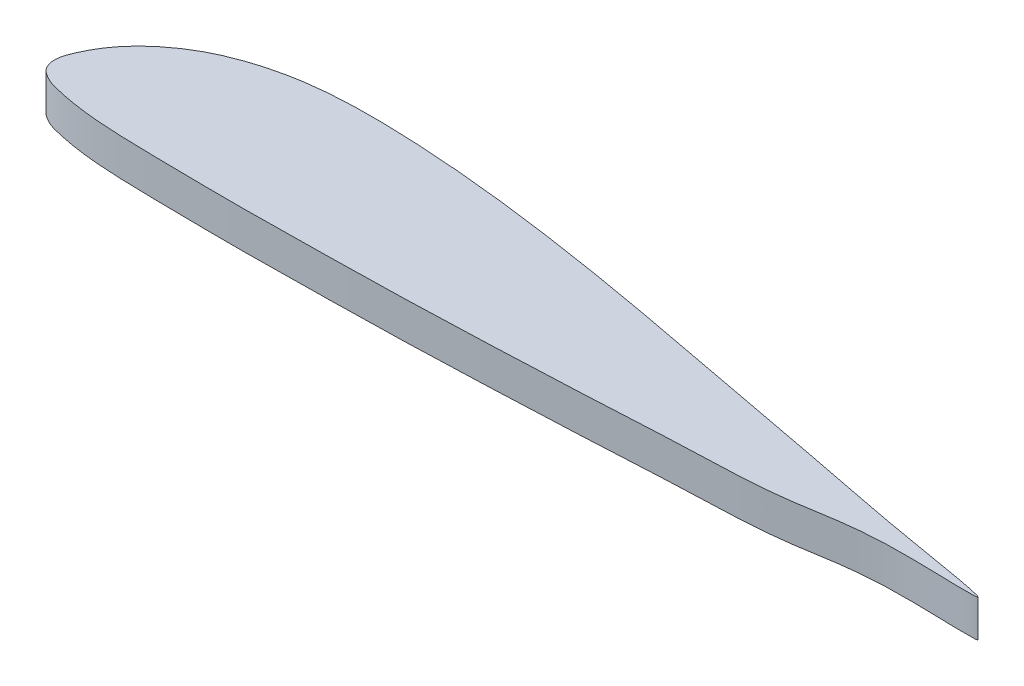
from build123d import *

# Parameters (mm, degrees)
BOSS_EXTRUDE2_DEPTH = 4


with BuildPart() as part:
    # Sketch2 → Boss-Extrude2 (new body)
    with BuildSketch(Plane(origin=(0, 0, 0), x_dir=(1, 0, 0), z_dir=(0, 1, 0))):
        with BuildLine():
            add(Edge.make_bspline(
                [(100, 0), (100.062832481, 0.251035491), (88.423782974, 2.077171545), (80.42251087, 3.753346357), (69.886173545, 5.709443028), (60.038664734, 7.607750011), (50.016738031, 9.448794891), (40.032646993, 10.974024804), (31.681442376, 11.857617234), (25.003732925, 12.218802233), (19.991287342, 12.255901671), (14.932026744, 11.831525262), (10.552698907, 10.717194811), (7.226014658, 9.264268293), (4.894142811, 7.740900366), (3.227317175, 6.302068696), (1.907577305, 4.784574924), (1.090513349, 3.517602977), (0.31110434, 1.94974357), (-0.274693213, 0.387957211), (0.322414802, -0.985991259), (1.128085986, -1.553275899), (1.960743073, -1.980402203), (3.325075799, -2.314398918), (4.988474859, -2.651519441), (7.325893482, -2.960829773), (10.662702275, -3.183298157), (14.99974317, -3.252309923), (19.999702383, -3.317990736), (25.000304183, -3.335714915), (31.666611827, -3.233615687), (40.004541812, -3.118802793), (49.993702731, -2.747917107), (60.032071472, -2.329079334), (69.887259845, -1.735293531), (80.450181756, -1.52889579), (88.417460145, 0.540970313), (99.938271834, -0.246623405), (100, 0)],
                knots=[0, 0, 0, 0, 0.049040866, 0.098081731, 0.147122597, 0.196163463, 0.245116686, 0.293834629, 0.342263553, 0.366385573, 0.390475046, 0.414675268, 0.439565651, 0.455415353, 0.466907824, 0.479711554, 0.487090329, 0.495936907, 0.501323477, 0.512663454, 0.51831006, 0.521365152, 0.526751722, 0.531754914, 0.54158153, 0.551304728, 0.565797224, 0.589894838, 0.613986045, 0.638075566, 0.662166773, 0.710353523, 0.758560308, 0.806785868, 0.855025, 0.903284915, 0.951821054, 1, 1, 1, 1], degree=3))
        make_face()
    extrude(amount=BOSS_EXTRUDE2_DEPTH)


solid = part.part
